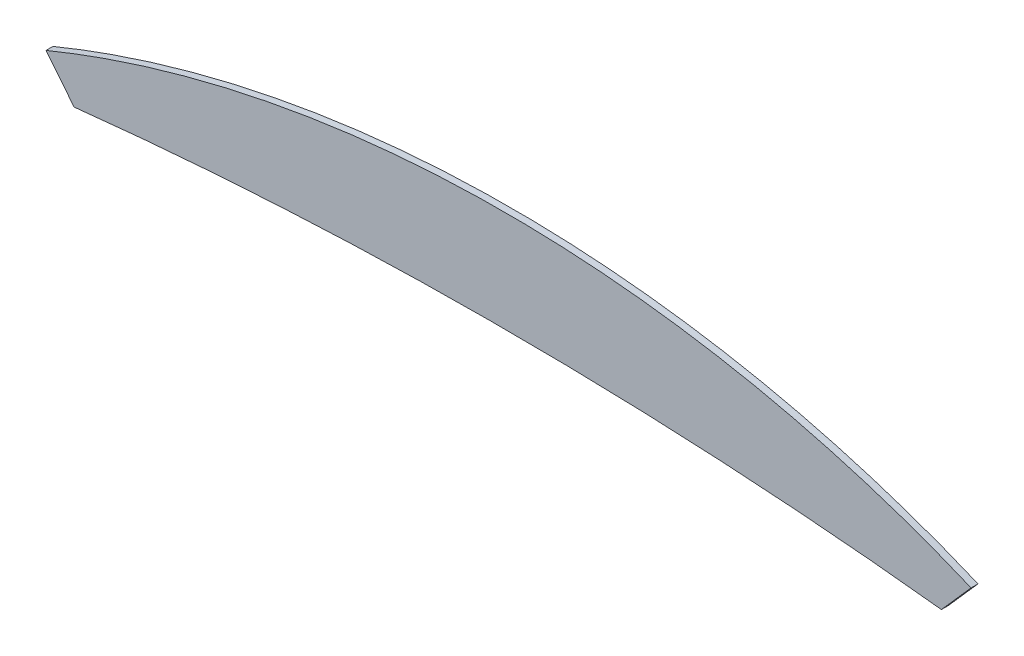
from build123d import *

# Parameters (mm, degrees)
SALIENTE_EXTRUIR1_DEPTH = 0.1


with BuildPart() as part:
    # Model → Saliente-Extruir1 (new body)
    with BuildSketch(Plane.XY):
        with BuildLine():
            add(Edge.make_bspline(
                [(45.683477537, 30.113649527), (45.480410217, 30.366499665), (45.277342898, 30.619349804)],
                knots=[2.235743312, 2.235743312, 2.235743312, 3.235743312, 3.235743312, 3.235743312], degree=2, weights=[1, 1, 1]))
            add(Edge.make_bspline(
                [(45.277342898, 30.619349804), (51.972636194, 33.386643804), (58.640402773, 30.577135941)],
                knots=[0, 0, 0, 0.961653513, 0.961653513, 0.961653513], degree=2, weights=[1, 0.886612841, 1]))
            add(Edge.make_bspline(
                [(58.640402773, 30.577135941), (58.426104972, 30.334197687), (58.211807171, 30.091259432)],
                knots=[0.961653513, 0.961653513, 0.961653513, 1.961653513, 1.961653513, 1.961653513], degree=2, weights=[1, 1, 1]))
            add(Edge.make_bspline(
                [(58.211807171, 30.091259432), (51.949572231, 30.793564024), (45.683477537, 30.113649527)],
                knots=[1.961653513, 1.961653513, 1.961653513, 2.235743312, 2.235743312, 2.235743312], degree=2, weights=[1, 0.990624036, 1]))
        make_face()
    extrude(amount=SALIENTE_EXTRUIR1_DEPTH)


solid = part.part
